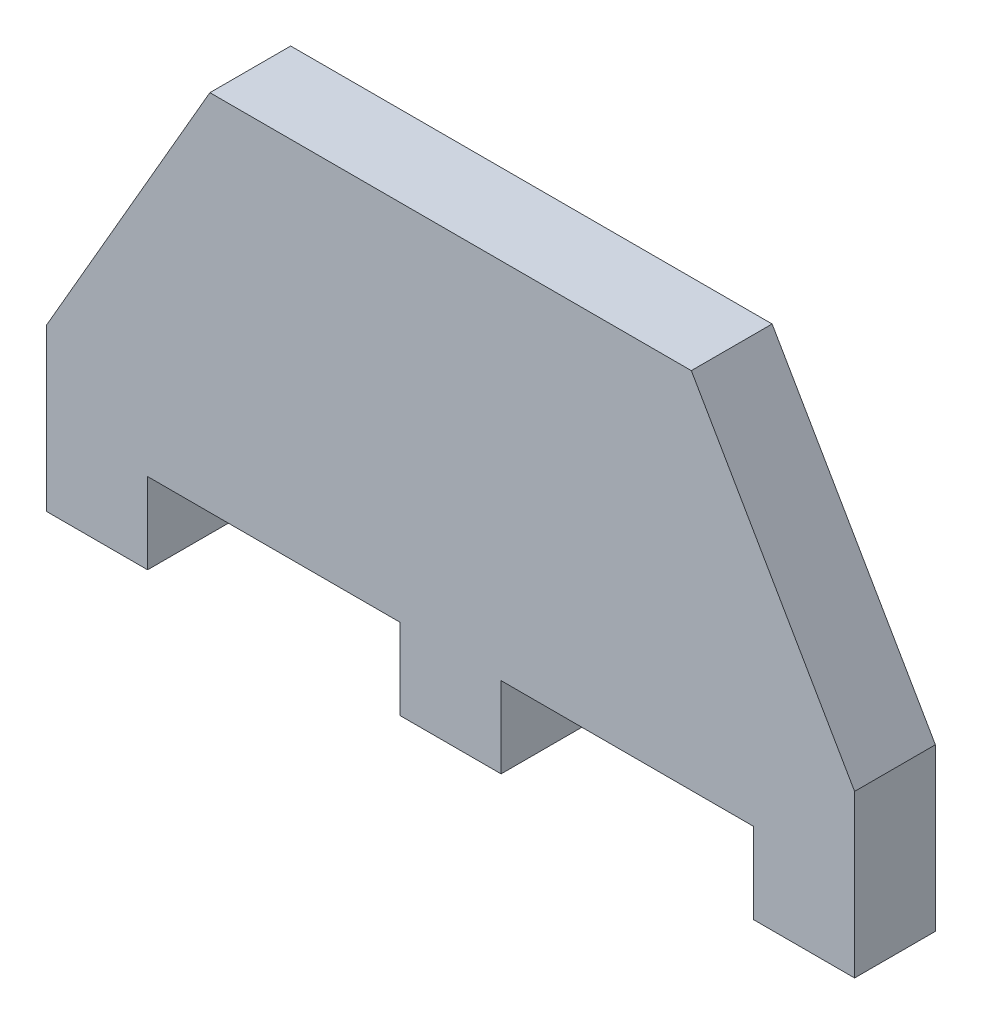
from build123d import *

# Parameters (mm, degrees)
BOSS_EXTRUDE1_DEPTH = 10


with BuildPart() as part:
    # Sketch1 → Boss-Extrude1 (new body)
    with BuildSketch(Plane.XY):
        Polygon((0, 0), (0, -10), (12.5, -10), (12.5, 0), (43.75, 0), (43.75, -10), (56.25, -10), (56.25, 0), (87.5, 0), (87.5, -10), (100, -10), (100, 0), (100, 10), (79.792740578, 45), (20.207259422, 45), (0, 10), align=None)
    extrude(amount=BOSS_EXTRUDE1_DEPTH)


solid = part.part
